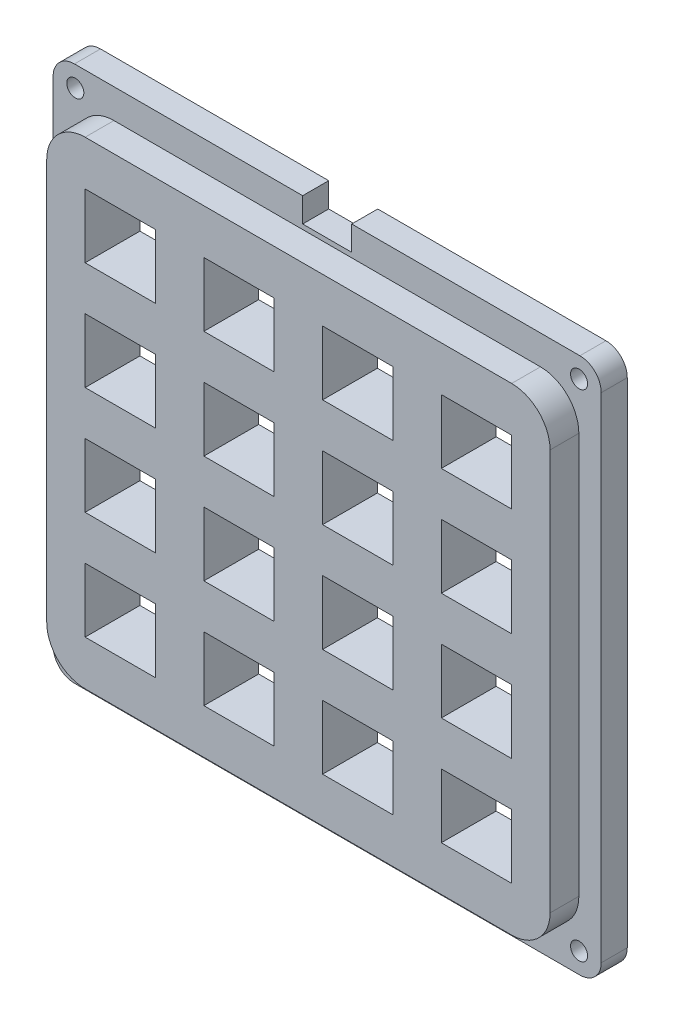
from build123d import *

# Parameters (mm, degrees)
BASE_DEPTH        = 3.0988
SKETCH4_R         = 1.016
MOUNT_HOLES_DEPTH = 4.0988
EXTRUDE2_DEPTH    = 3.429
SKETCH3_W         = 8.382
SKETCH3_H         = 7.62
KEY_DEPTH         = 7.5278
KEYS_COUNT        = 4
KEYS_PITCH        = 14.14018
KEYS_COUNT_DIR2   = 4
KEYS_PITCH_DIR2   = 12.869418


with BuildPart() as part:
    # Sketch1 → base (new body)
    with BuildSketch(Plane.XY):
        with BuildLine():
            Line((-2.921, 31.9405), (-30.099, 31.9405))
            ThreePointArc((-30.099, 31.9405), (-31.895051224, 31.196551224), (-32.639, 29.4005))
            Line((-32.639, 29.4005), (-32.639, -29.4005))
            ThreePointArc((-32.639, -29.4005), (-31.895051224, -31.196551224), (-30.099, -31.9405))
            Line((-30.099, -31.9405), (30.099, -31.9405))
            ThreePointArc((30.099, -31.9405), (31.895051224, -31.196551224), (32.639, -29.4005))
            Line((32.639, -29.4005), (32.639, 29.4005))
            ThreePointArc((32.639, 29.4005), (31.895051224, 31.196551224), (30.099, 31.9405))
            Line((30.099, 31.9405), (2.921, 31.9405))
            Line((2.921, 31.9405), (2.921, 29.0195))
            Line((2.921, 29.0195), (-2.921, 29.0195))
            Line((-2.921, 29.0195), (-2.921, 31.9405))
        make_face()
    extrude(amount=BASE_DEPTH)

    # Sketch4 → mount holes (cut, through all)
    with BuildSketch(Plane.XY.offset(3.0988)):
        with Locations((-30, 29.5)):
            Circle(SKETCH4_R)
        with Locations((30, 29.5)):
            Circle(SKETCH4_R)
        with Locations((30, -29.5)):
            Circle(SKETCH4_R)
        with Locations((-30, -29.5)):
            Circle(SKETCH4_R)
    extrude(amount=-MOUNT_HOLES_DEPTH, mode=Mode.SUBTRACT)

    # Sketch2 → Extrude2 (add)
    with BuildSketch(Plane.XY.offset(3.0988)):
        with BuildLine():
            Line((-25.4, 28.448), (25.4, 28.448))
            ThreePointArc((25.4, 28.448), (28.632892204, 27.108892204), (29.972, 23.876))
            Line((29.972, 23.876), (29.972, -23.876))
            ThreePointArc((29.972, -23.876), (28.632892204, -27.108892204), (25.4, -28.448))
            Line((25.4, -28.448), (-25.4, -28.448))
            ThreePointArc((-25.4, -28.448), (-28.632892204, -27.108892204), (-29.972, -23.876))
            Line((-29.972, -23.876), (-29.972, 23.876))
            ThreePointArc((-29.972, 23.876), (-28.632892204, 27.108892204), (-25.4, 28.448))
        make_face()
    extrude(amount=EXTRUDE2_DEPTH)

    # Sketch3 → key (cut, through all)
    with BuildSketch(Plane.XY.offset(6.5278)):
        with Locations((-21.209, 19.304)):
            Rectangle(SKETCH3_W, SKETCH3_H)
    key = extrude(amount=-KEY_DEPTH, mode=Mode.SUBTRACT)

    # keys: key 4 × 4
    with Locations(*[(i * KEYS_PITCH, -j * KEYS_PITCH_DIR2, 0) for i in range(KEYS_COUNT) for j in range(KEYS_COUNT_DIR2) if (i, j) != (0, 0)]):
        add(key, mode=Mode.SUBTRACT)


solid = part.part
